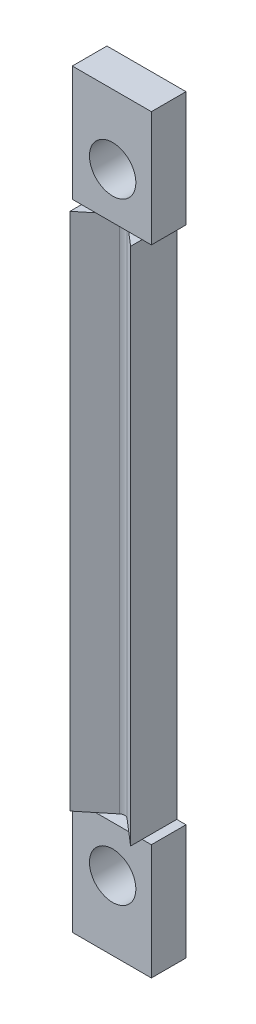
from build123d import *

# Parameters (mm, degrees)
BOSS_EXTRUDE1_DEPTH = 22.5
SKETCH2_W           = 6.85
SKETCH2_H           = 3
BOSS_EXTRUDE2_DEPTH = 10
SKETCH3_W           = 6.85
SKETCH3_H           = 3
BOSS_EXTRUDE3_DEPTH = 10
FILLET2_R           = 0.5
SKETCH5_R           = 2.01
CUT_EXTRUDE1_DEPTH  = 10


with BuildPart() as part:
    # Sketch1 → Boss-Extrude1 (new body, symmetric)
    with BuildSketch(Plane(origin=(0, 0, 0), x_dir=(1, 0, 0), z_dir=(0, 1, 0))):
        Polygon((0, 0), (-2.69457677, -2.2), (-2.69457677, 1.8), (2.55542323, 1.8), (2.55542323, -2.2), align=None)
    extrude(amount=BOSS_EXTRUDE1_DEPTH, both=True)

    # Sketch2 → Boss-Extrude2 (add)
    with BuildSketch(Plane(origin=(0, 22.5, 0), x_dir=(1, 0, 0), z_dir=(0, 1, 0))):
        with Locations((-0.06957677, 0.3)):
            Rectangle(SKETCH2_W, SKETCH2_H)
    extrude(amount=BOSS_EXTRUDE2_DEPTH)

    # Sketch3 → Boss-Extrude3 (add)
    with BuildSketch(Plane.XZ.offset(22.5)):
        with Locations((-0.06957677, -0.3)):
            Rectangle(SKETCH3_W, SKETCH3_H)
    extrude(amount=BOSS_EXTRUDE3_DEPTH)

    # Fillet2
    fillet2_edges = [part.edges().sort_by_distance(p)[0] for p in [
        (0, 0, 0),
    ]]
    fillet(fillet2_edges, radius=FILLET2_R)

    # Sketch5 → Cut-Extrude1 (cut)
    with BuildSketch(Plane(origin=(0, 0, -1.8), x_dir=(-1, 0, 0), z_dir=(0, 0, -1))):
        with Locations((0, -26.5)):
            Circle(SKETCH5_R)
        with Locations((0, 26.5)):
            Circle(SKETCH5_R)
    extrude(amount=-CUT_EXTRUDE1_DEPTH, mode=Mode.SUBTRACT)


solid = part.part
